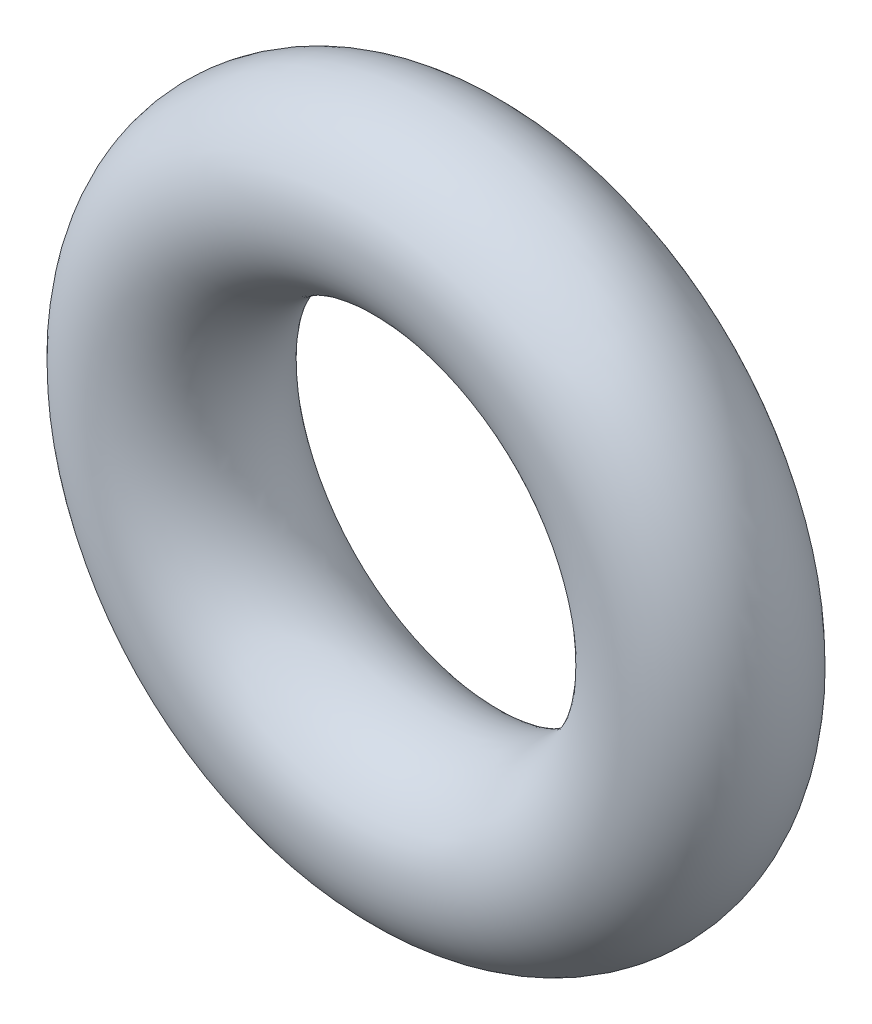
from build123d import *

# Parameters (mm, degrees)
SKETCH1_R = 1.3081


with BuildPart() as part:
    # Sketch1 → Revolve1 (revolve)
    with BuildSketch(Plane(origin=(0, 0, 0), x_dir=(0, -1, 0), z_dir=(1, 0, 0))):
        with Locations((3.9243, 0)):
            Circle(SKETCH1_R)
    revolve(axis=Axis((0, 0, 1.3081), (0, 0, -1)))


solid = part.part
